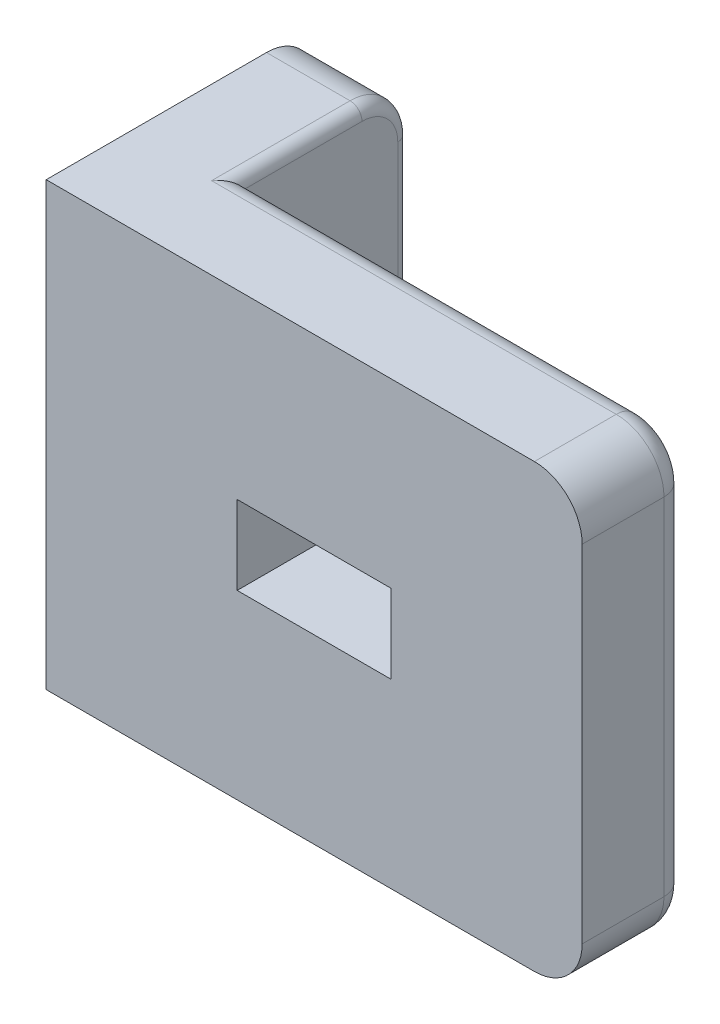
from build123d import *

# Parameters (mm, degrees)
BOSS_EXTRUDE1_DEPTH = 18.5
SKETCH2_W           = 6.45
SKETCH2_H           = 3.3
CUT_EXTRUDE1_DEPTH  = 4.5
SKETCH3_R           = 2.25
CUT_EXTRUDE2_DEPTH  = 1.75
SKETCH4_R           = 1.15
CUT_EXTRUDE3_DEPTH  = 2.3
FILLET3_R           = 2
FILLET4_R           = 2
FILLET5_R           = 2
FILLET6_R           = 2
FILLET7_R           = 1
FILLET8_R           = 0.5
FILLET9_R           = 1
FILLET10_R          = 1
FILLET12_R          = 0.5


with BuildPart() as part:
    # Sketch1 → Boss-Extrude1 (new body)
    with BuildSketch(Plane(origin=(0, 0, 0), x_dir=(1, 0, 0), z_dir=(0, 1, 0))):
        Polygon((0, 0), (0, 11.227239651), (4, 11.227239651), (4, 4.427239651), (22.45, 4.427239651), (22.45, 0), align=None)
    extrude(amount=BOSS_EXTRUDE1_DEPTH)

    # Sketch2 → Cut-Extrude1 (cut)
    with BuildSketch(Plane.XY):
        with Locations((11.225, 9.25)):
            Rectangle(SKETCH2_W, SKETCH2_H)
    extrude(amount=-CUT_EXTRUDE1_DEPTH, mode=Mode.SUBTRACT)

    # Sketch3 → Cut-Extrude2 (cut)
    with BuildSketch(Plane(origin=(4, 0, 0), x_dir=(0, 0, -1), z_dir=(1, 0, 0))):
        with Locations((7.827239651, 9.25)):
            Circle(SKETCH3_R)
    extrude(amount=-CUT_EXTRUDE2_DEPTH, mode=Mode.SUBTRACT)

    # Sketch4 → Cut-Extrude3 (cut)
    with BuildSketch(Plane(origin=(2.25, 0, 0), x_dir=(0, 0, -1), z_dir=(1, 0, 0))):
        with Locations((7.827239651, 9.25)):
            Circle(SKETCH4_R)
    extrude(amount=-CUT_EXTRUDE3_DEPTH, mode=Mode.SUBTRACT)

    # Fillet3
    fillet3_edges = [part.edges().sort_by_distance(p)[0] for p in [
        (2, 18.5, -11.227239651),
    ]]
    fillet(fillet3_edges, radius=FILLET3_R)

    # Fillet4
    fillet4_edges = [part.edges().sort_by_distance(p)[0] for p in [
        (2, 0, -11.227239651),
    ]]
    fillet(fillet4_edges, radius=FILLET4_R)

    # Fillet5
    fillet5_edges = [part.edges().sort_by_distance(p)[0] for p in [
        (22.45, 0, -2.213619825),
    ]]
    fillet(fillet5_edges, radius=FILLET5_R)

    # Fillet6
    fillet6_edges = [part.edges().sort_by_distance(p)[0] for p in [
        (22.45, 18.5, -2.213619825),
    ]]
    fillet(fillet6_edges, radius=FILLET6_R)

    # Fillet7
    fillet7_edges = [part.edges().sort_by_distance(p)[0] for p in [
        (11.225, 10.9, -4.427239651),
        (8, 9.25, -4.427239651),
        (11.225, 7.6, -4.427239651),
        (14.45, 9.25, -4.427239651),
    ]]
    fillet(fillet7_edges, radius=FILLET7_R)

    # Fillet8
    fillet8_edges = [part.edges().sort_by_distance(p)[0] for p in [
        (4, 9.25, -5.577239651),
    ]]
    fillet(fillet8_edges, radius=FILLET8_R)

    # Fillet9
    fillet9_edges = [part.edges().sort_by_distance(p)[0] for p in [
        (2.25, 9.25, -5.577239651),
    ]]
    fillet(fillet9_edges, radius=FILLET9_R)

    # Fillet10
    fillet10_edges = [part.edges().sort_by_distance(p)[0] for p in [
        (12.225, 0, -4.427239651),
        (21.864213562, 0.585786438, -4.427239651),
        (12.225, 18.5, -4.427239651),
        (22.45, 9.25, -4.427239651),
        (21.864213562, 17.914213562, -4.427239651),
    ]]
    fillet(fillet10_edges, radius=FILLET10_R)

    # Fillet12
    fillet12_edges = [part.edges().sort_by_distance(p)[0] for p in [
        (4, 18.5, -6.827239651),
        (4, 9.25, -11.227239651),
        (4, 17.914213562, -10.641453213),
        (4, 0.585786438, -10.641453213),
        (4, 0, -6.827239651),
    ]]
    fillet(fillet12_edges, radius=FILLET12_R)


solid = part.part
